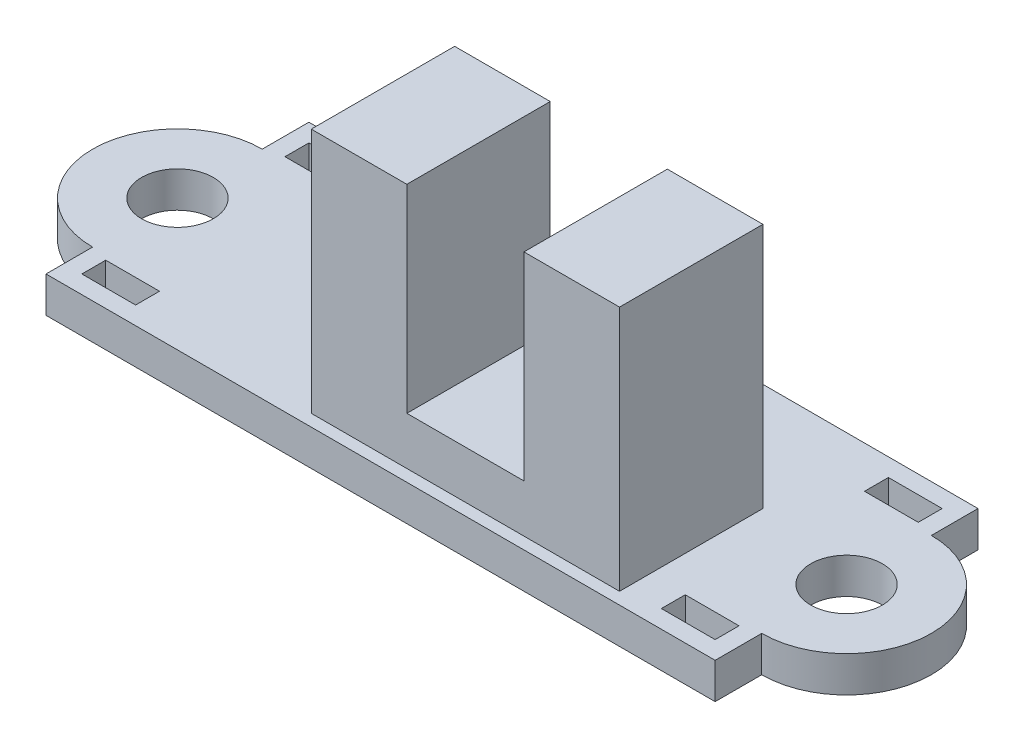
from build123d import *

# Parameters (mm, degrees)
SKETCH1_R         = 1.5
PCB_DEPTH         = 1.5
SKETCH2_W         = 2.25
SKETCH2_H         = 1
TAB_SLOTS_DEPTH   = 2.5
SKETCH3_W         = 12.9
SKETCH3_H         = 6
SENSOR_BODY_DEPTH = 10.3
SKETCH4_W         = 4.9
SKETCH4_H         = 6
SENSOR_SLOT_DEPTH = 8.3


with BuildPart() as part:
    # Sketch1 → PCB (new body)
    with BuildSketch(Plane(origin=(0, 0, 0), x_dir=(1, 0, 0), z_dir=(0, 1, 0))):
        with BuildLine():
            Line((-14, 3.55), (-14, 5.5))
            Line((-14, 5.5), (14, 5.5))
            Line((14, 5.5), (14, 3.55))
            ThreePointArc((14, 3.55), (17.55, 0), (14, -3.55))
            Line((14, -3.55), (14, -5.5))
            Line((14, -5.5), (-14, -5.5))
            Line((-14, -5.5), (-14, -3.55))
            ThreePointArc((-14, -3.55), (-17.55, 0), (-14, 3.55))
        make_face()
        with Locations((-14, 0)):
            Circle(SKETCH1_R, mode=Mode.SUBTRACT)
        with Locations((14, 0)):
            Circle(SKETCH1_R, mode=Mode.SUBTRACT)
    extrude(amount=PCB_DEPTH)

    # Sketch2 → Tab Slots (cut, through all)
    with BuildSketch(Plane(origin=(0, 1.5, 0), x_dir=(1, 0, 0), z_dir=(0, 1, 0))):
        with Locations((-12.125, -4.25)):
            Rectangle(SKETCH2_W, SKETCH2_H)
        with Locations((-12.125, 4.25)):
            Rectangle(SKETCH2_W, SKETCH2_H)
        with Locations((12.125, 4.25)):
            Rectangle(SKETCH2_W, SKETCH2_H)
        with Locations((12.125, -4.25)):
            Rectangle(SKETCH2_W, SKETCH2_H)
    extrude(amount=-TAB_SLOTS_DEPTH, mode=Mode.SUBTRACT)


with BuildPart() as body_2:
    # Sketch3 → Sensor Body (new body)
    with BuildSketch(Plane(origin=(0, 1.5, 0), x_dir=(1, 0, 0), z_dir=(0, 1, 0))):
        with Locations((3.05, -2)):
            Rectangle(SKETCH3_W, SKETCH3_H)
    extrude(amount=SENSOR_BODY_DEPTH)

    # Sketch4 → Sensor Slot (cut)
    with BuildSketch(Plane(origin=(0, 11.8, 0), x_dir=(1, 0, 0), z_dir=(0, 1, 0))):
        with Locations((3.05, -2)):
            Rectangle(SKETCH4_W, SKETCH4_H)
    extrude(amount=-SENSOR_SLOT_DEPTH, mode=Mode.SUBTRACT)


solid = Compound([part.part, body_2.part])
